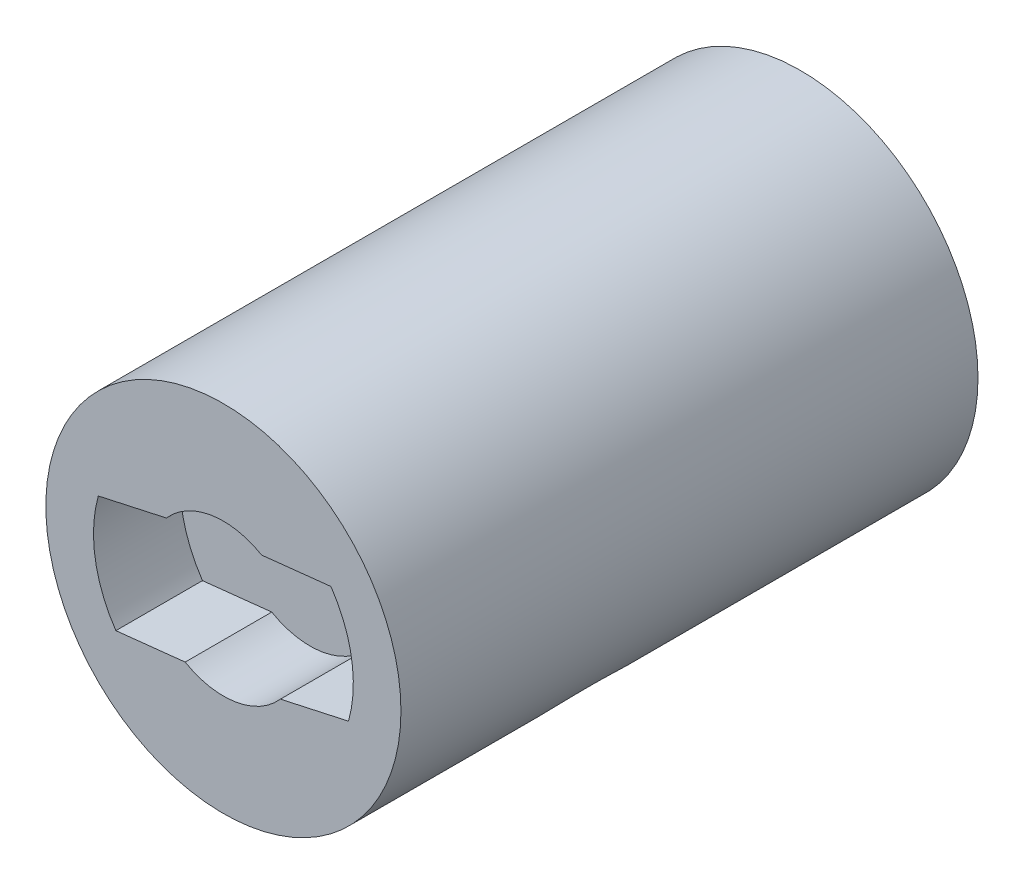
from build123d import *

# Parameters (mm, degrees)
SKETCH_1_R          = 8.2
EXTRUDE_1_DEPTH     = 26.65
SKETCH_3_R          = 5
EXTRUDE_2_DEPTH     = 1.5
CUT_EXTRUDE_1_DEPTH = 4
CUT_EXTRUDE_START   = -1
SKETCH_5_R          = 6.25
CUT_EXTRUDE_2_DEPTH = 10


with BuildPart() as part:
    # Эскиз1 → Бобышка-Вытянуть1 (new body)
    with BuildSketch(Plane.XY):
        Circle(SKETCH_1_R)
    extrude(amount=EXTRUDE_1_DEPTH)

    # Эскиз3 → Бобышка-Вытянуть2 (add)
    with BuildSketch(Plane(origin=(0, 0, 0), x_dir=(-1, 0, 0), z_dir=(0, 0, -1))):
        Circle(SKETCH_3_R)
    extrude(amount=EXTRUDE_2_DEPTH)

    # Эскиз4 → Вырез-Вытянуть1 (cut)
    with BuildSketch(Plane.XY.offset(26.65)):
        with BuildLine():
            ThreePointArc((1.764967336, 3.022398105), (-0.563166375, 3.454394829), (-2.63353871, 2.305314265))
            Line((-2.63353871, 2.305314265), (-5.778686809, 1.614552185))
            ThreePointArc((-5.778686809, 1.614552185), (-5.921819707, -0.965428072), (-4.966654884, -3.366354001))
            Line((-4.966654884, -3.366354001), (-1.764967336, -3.022398105))
            ThreePointArc((-1.764967336, -3.022398105), (0.563166375, -3.454394829), (2.63353871, -2.305314265))
            Line((2.63353871, -2.305314265), (5.778686809, -1.614552185))
            ThreePointArc((5.778686809, -1.614552185), (5.944414221, -0.814824872), (6, 0))
            ThreePointArc((6, 0), (5.735849079, 1.760691724), (4.966654884, 3.366354001))
            Line((4.966654884, 3.366354001), (1.764967336, 3.022398105))
        make_face()
    extrude(amount=-CUT_EXTRUDE_1_DEPTH, mode=Mode.SUBTRACT)

    # Эскиз5 → Вырез-Вытянуть2 (cut)
    with BuildSketch(Plane(origin=(0, 0, 0), x_dir=(1, 0, 0), z_dir=(0, 1, 0)).offset(CUT_EXTRUDE_START)):
        with Locations((0, -16)):
            Circle(SKETCH_5_R)
    extrude(amount=-CUT_EXTRUDE_2_DEPTH, mode=Mode.SUBTRACT)


solid = part.part
